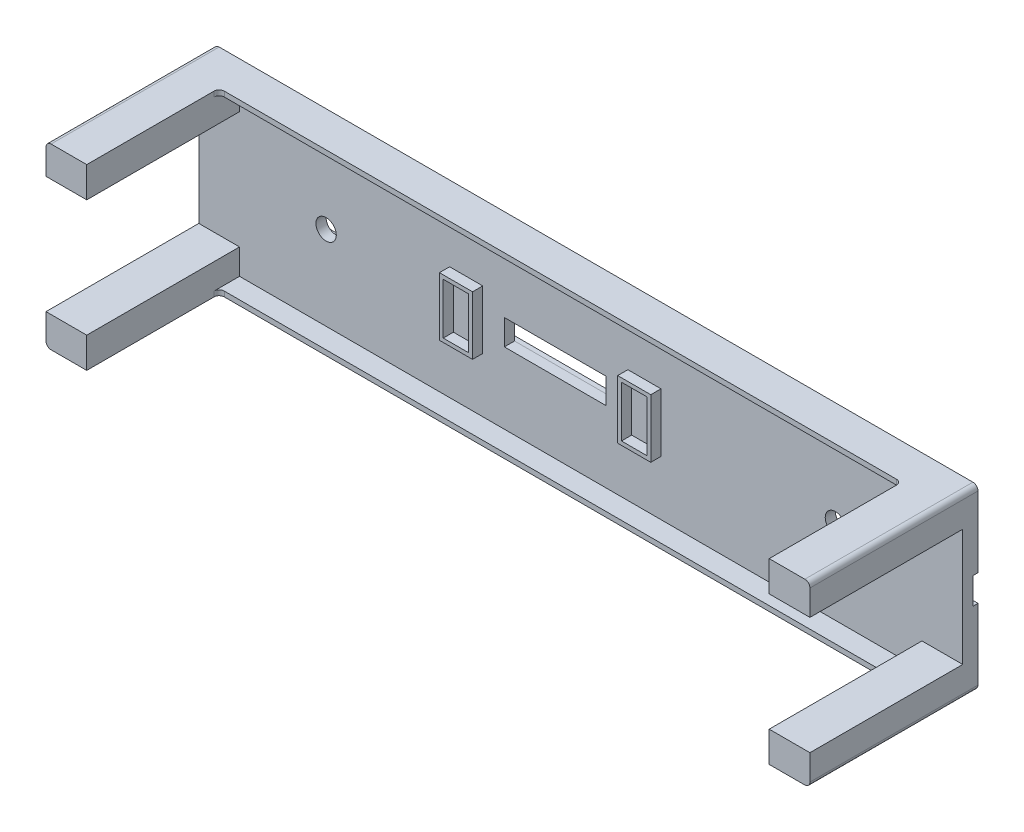
from build123d import *

# Parameters (mm, degrees)
SKICA1_W                 = 150
SKICA1_H                 = 35
P_IDAT_VYSUNUT_M2_DEPTH  = 3
SKICA2_W                 = 6.5
SKICA2_H                 = 11.5
SKICA2_W_2               = 5
SKICA2_H_2               = 10
P_IDAT_VYSUNUT_M3_DEPTH  = 2
SKICA4_W                 = 20
SKICA4_H                 = 5
ODEBRAT_VYSUNUT_M1_DEPTH = 2
SKICA5_W                 = 150
SKICA5_H                 = 5.2
ODEBRAT_VYSUNUT_M3_DEPTH = 1
SKICA7_R                 = 2
ODEBRAT_VYSUNUT_M4_DEPTH = 5
SKICA8_W                 = 8
SKICA8_H                 = 6
P_IDAT_VYSUNUT_M4_DEPTH  = 30
ZAOBLIT1_R               = 1
SKICA9_W                 = 134
SKICA9_H                 = 1
P_IDAT_VYSUNUT_M5_DEPTH  = 4
ZAOBLIT2_R               = 1


with BuildPart() as part:
    # Skica1 → Přidat vysunutím2 (new body)
    with BuildSketch(Plane.XY):
        Rectangle(SKICA1_W, SKICA1_H)
    extrude(amount=P_IDAT_VYSUNUT_M2_DEPTH)

    # Skica2 → Přidat vysunutím3 (add)
    with BuildSketch(Plane.XY.offset(3)):
        with Locations((-22.5, 0)):
            Rectangle(SKICA2_W, SKICA2_H)
        with Locations((-22.5, 0)):
            Rectangle(SKICA2_W_2, SKICA2_H_2, mode=Mode.SUBTRACT)
        with Locations((12.5, 0)):
            Rectangle(SKICA2_W, SKICA2_H)
        with Locations((12.5, 0)):
            Rectangle(SKICA2_W_2, SKICA2_H_2, mode=Mode.SUBTRACT)
    extrude(amount=P_IDAT_VYSUNUT_M3_DEPTH)

    # Skica4 → Odebrat vysunutím1 (cut)
    with BuildSketch(Plane.XY.offset(3)):
        with Locations((-5, 0)):
            Rectangle(SKICA4_W, SKICA4_H)
    extrude(amount=-ODEBRAT_VYSUNUT_M1_DEPTH, mode=Mode.SUBTRACT)

    # Skica5 → Odebrat vysunutím3 (cut)
    with BuildSketch(Plane(origin=(0, 0, 0), x_dir=(-1, 0, 0), z_dir=(0, 0, -1))):
        Rectangle(SKICA5_W, SKICA5_H)
    extrude(amount=-ODEBRAT_VYSUNUT_M3_DEPTH, mode=Mode.SUBTRACT)

    # Skica7 → Odebrat vysunutím4 (cut, through all)
    with BuildSketch(Plane(origin=(0, 0, 1), x_dir=(-1, 0, 0), z_dir=(0, 0, -1))):
        with Locations((-50, 0)):
            Circle(SKICA7_R)
        with Locations((50, 0)):
            Circle(SKICA7_R)
    extrude(amount=-ODEBRAT_VYSUNUT_M4_DEPTH, mode=Mode.SUBTRACT)

    # Skica8 → Přidat vysunutím4 (add)
    with BuildSketch(Plane.XY.offset(3)):
        with Locations((71, 14.5)):
            Rectangle(SKICA8_W, SKICA8_H)
        with Locations((71, -14.5)):
            Rectangle(SKICA8_W, SKICA8_H)
        with Locations((-71, -14.5)):
            Rectangle(SKICA8_W, SKICA8_H)
        with Locations((-71, 14.5)):
            Rectangle(SKICA8_W, SKICA8_H)
    extrude(amount=P_IDAT_VYSUNUT_M4_DEPTH)

    # Zaoblit1
    zaoblit1_edges = [part.edges().sort_by_distance(p)[0] for p in [
        (75, -17.5, 16.5),
        (75, 17.5, 16.5),
        (-75, 17.5, 16.5),
        (-75, -17.5, 16.5),
    ]]
    fillet(zaoblit1_edges, radius=ZAOBLIT1_R)

    # Skica9 → Přidat vysunutím5 (add)
    with BuildSketch(Plane.XY.offset(3)):
        with Locations((0, 17)):
            Rectangle(SKICA9_W, SKICA9_H)
        with Locations((0, -17)):
            Rectangle(SKICA9_W, SKICA9_H)
    extrude(amount=P_IDAT_VYSUNUT_M5_DEPTH)

    # Zaoblit2
    zaoblit2_edges = [part.edges().sort_by_distance(p)[0] for p in [
        (67, 17, 7),
        (-67, 17, 7),
        (-67, -17, 7),
        (67, -17, 7),
    ]]
    fillet(zaoblit2_edges, radius=ZAOBLIT2_R)


solid = part.part
